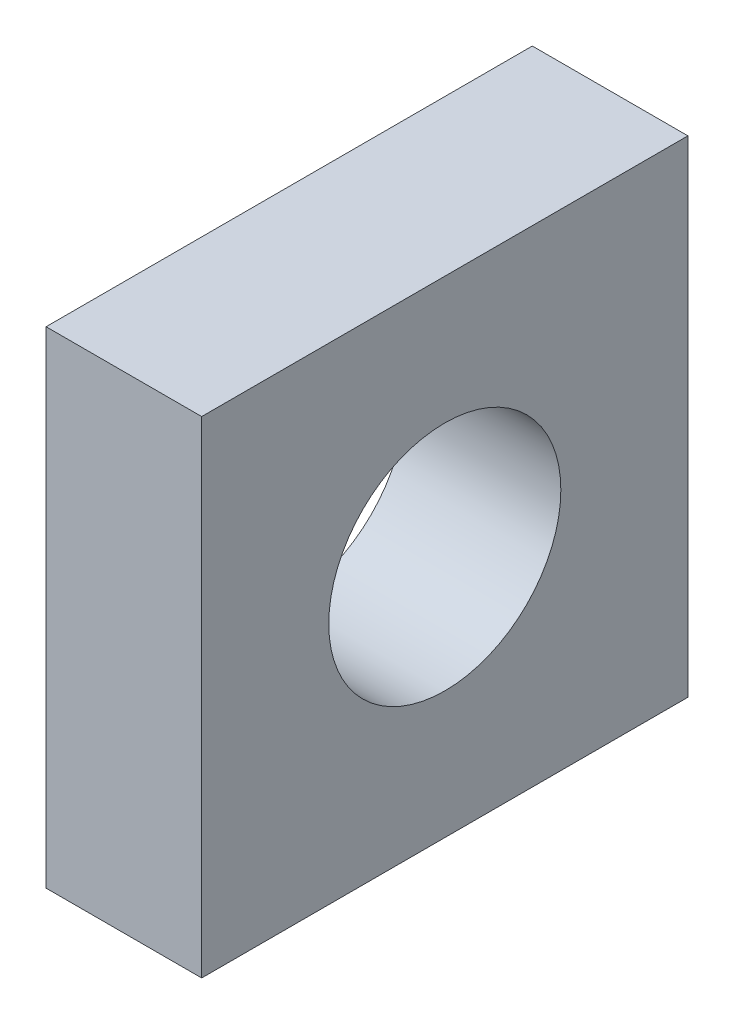
from build123d import *

# Parameters (mm, degrees)
SKETCH1_W           = 10
SKETCH1_H           = 10
SKETCH1_R           = 2.38655
BOSS_EXTRUDE1_DEPTH = 3.2


with BuildPart() as part:
    # Sketch1 → Boss-Extrude1 (new body)
    with BuildSketch(Plane(origin=(3.4, 0, 0), x_dir=(0, -1, 0), z_dir=(-1, 0, 0))):
        with Locations((-14, 34)):
            Rectangle(SKETCH1_W, SKETCH1_H)
        with Locations((-14, 34)):
            Circle(SKETCH1_R, mode=Mode.SUBTRACT)
    extrude(amount=-BOSS_EXTRUDE1_DEPTH)


solid = part.part
